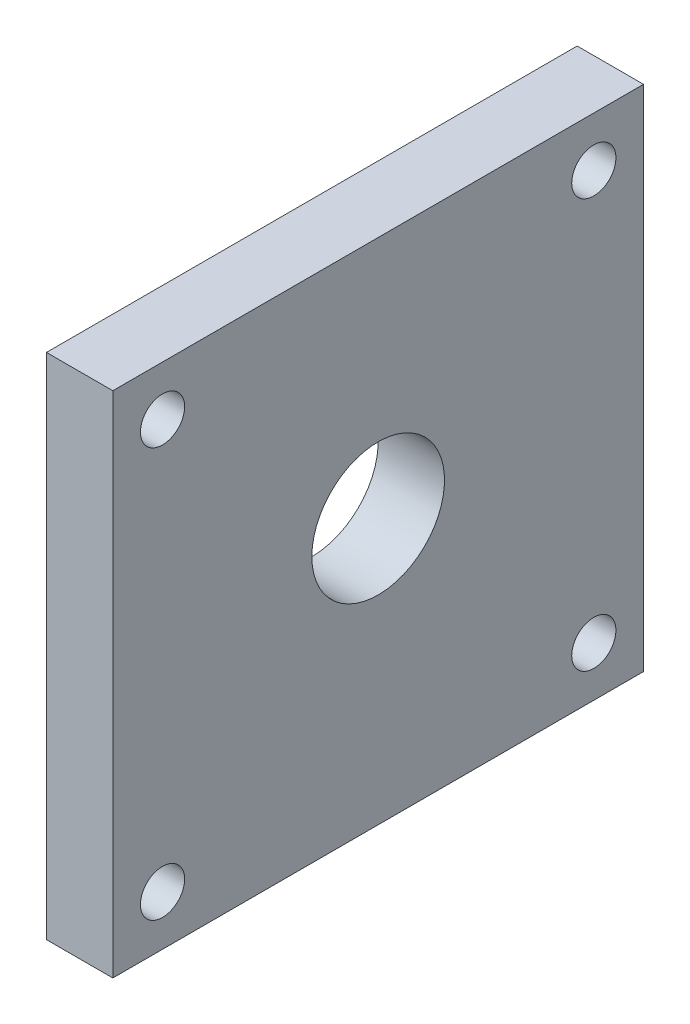
from build123d import *

# Parameters (mm, degrees)
SKETCH1_W          = 76.2
SKETCH1_H          = 73.025
EXTRUDE1_DEPTH     = 9.525
SKETCH8_R          = 3.175
SKETCH8_R_2        = 9.525
CUT_EXTRUDE5_DEPTH = 10.525


with BuildPart() as part:
    # Sketch1 → Extrude1 (new body)
    with BuildSketch(Plane(origin=(0, 0, 0), x_dir=(0, 0, -1), z_dir=(1, 0, 0))):
        with Locations((38.1, -36.5125)):
            Rectangle(SKETCH1_W, SKETCH1_H)
    extrude(amount=EXTRUDE1_DEPTH)

    # Sketch8 → Cut-Extrude5 (cut, through all)
    with BuildSketch(Plane.ZY):
        with Locations((-7.1374, -7.1374)):
            Circle(SKETCH8_R)
        with Locations((-69.0626, -7.1374)):
            Circle(SKETCH8_R)
        with Locations((-69.0626, -65.8876)):
            Circle(SKETCH8_R)
        with Locations((-7.1374, -65.8876)):
            Circle(SKETCH8_R)
        with Locations((-38.1, -34.925)):
            Circle(SKETCH8_R_2)
    extrude(amount=-CUT_EXTRUDE5_DEPTH, mode=Mode.SUBTRACT)


solid = part.part
